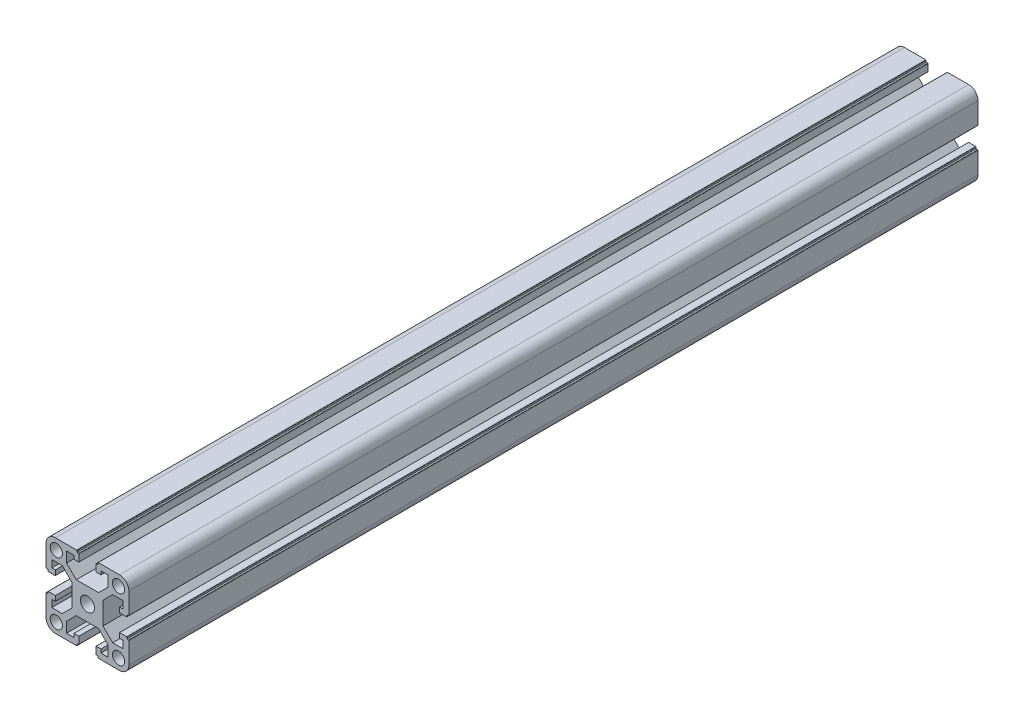
from build123d import *

# Parameters (mm, degrees)
SKETCH_1_R          = 2.95
SKETCH_1_R_2        = 3.4
EXTRUDE_1_DEPTH     = 205
SKETCH_2_R          = 4
CUT_EXTRUDE_1_DEPTH = 102


with BuildPart() as part:
    # 草图1 → 凸台-拉伸1 (new body, symmetric)
    with BuildSketch(Plane.XY.offset(50)):
        with BuildLine():
            Line((-1518.245004392, 3588.004280474), (-1518.245004392, 3582.975600817))
            Line((-1518.245004392, 3582.975600817), (-1522.916324736, 3578.304280474))
            Line((-1522.916324736, 3578.304280474), (-1533.673684048, 3578.304280474))
            Line((-1533.673684048, 3578.304280474), (-1538.345004392, 3582.975600817))
            Line((-1538.345004392, 3582.975600817), (-1538.345004392, 3588.004280474))
            Line((-1538.345004392, 3588.004280474), (-1534.845004392, 3588.004280474))
            Line((-1534.845004392, 3588.004280474), (-1534.845004392, 3586.304280474))
            Line((-1534.845004392, 3586.304280474), (-1532.445004392, 3586.304280474))
            Line((-1532.445004392, 3586.304280474), (-1532.445004392, 3589.704280474))
            ThreePointArc((-1532.445004392, 3589.704280474), (-1532.503583036, 3589.84570183), (-1532.645004392, 3589.904280474))
            Line((-1532.645004392, 3589.904280474), (-1533.345004392, 3589.904280474))
            Line((-1533.345004392, 3589.904280474), (-1533.345004392, 3590.604280474))
            ThreePointArc((-1533.345004392, 3590.604280474), (-1533.403583036, 3590.74570183), (-1533.545004392, 3590.804280474))
            Line((-1533.545004392, 3590.804280474), (-1543.795004392, 3590.804280474))
            ThreePointArc((-1543.795004392, 3590.804280474), (-1546.976984907, 3589.486260989), (-1548.295004392, 3586.304280474))
            Line((-1548.295004392, 3586.304280474), (-1548.295004392, 3576.054280474))
            ThreePointArc((-1548.295004392, 3576.054280474), (-1548.236425748, 3575.912859117), (-1548.095004392, 3575.854280474))
            Line((-1548.095004392, 3575.854280474), (-1547.395004392, 3575.854280474))
            Line((-1547.395004392, 3575.854280474), (-1547.395004392, 3575.154280474))
            ThreePointArc((-1547.395004392, 3575.154280474), (-1547.336425748, 3575.012859117), (-1547.195004392, 3574.954280474))
            Line((-1547.195004392, 3574.954280474), (-1543.795004392, 3574.954280474))
            Line((-1543.795004392, 3574.954280474), (-1543.795004392, 3577.354280474))
            Line((-1543.795004392, 3577.354280474), (-1545.495004392, 3577.354280474))
            Line((-1545.495004392, 3577.354280474), (-1545.495004392, 3580.854280474))
            Line((-1545.495004392, 3580.854280474), (-1540.466324736, 3580.854280474))
            Line((-1540.466324736, 3580.854280474), (-1535.795004392, 3576.18296013))
            Line((-1535.795004392, 3576.18296013), (-1535.795004392, 3565.425600817))
            Line((-1535.795004392, 3565.425600817), (-1540.466324736, 3560.754280474))
            Line((-1540.466324736, 3560.754280474), (-1545.495004392, 3560.754280474))
            Line((-1545.495004392, 3560.754280474), (-1545.495004392, 3564.254280474))
            Line((-1545.495004392, 3564.254280474), (-1543.795004392, 3564.254280474))
            Line((-1543.795004392, 3564.254280474), (-1543.795004392, 3566.654280474))
            Line((-1543.795004392, 3566.654280474), (-1547.195004392, 3566.654280474))
            ThreePointArc((-1547.195004392, 3566.654280474), (-1547.336425748, 3566.59570183), (-1547.395004392, 3566.454280474))
            Line((-1547.395004392, 3566.454280474), (-1547.395004392, 3565.754280474))
            Line((-1547.395004392, 3565.754280474), (-1548.095004392, 3565.754280474))
            ThreePointArc((-1548.095004392, 3565.754280474), (-1548.236425748, 3565.69570183), (-1548.295004392, 3565.554280474))
            Line((-1548.295004392, 3565.554280474), (-1548.295004392, 3555.304280474))
            ThreePointArc((-1548.295004392, 3555.304280474), (-1546.976984907, 3552.122299958), (-1543.795004392, 3550.804280474))
            Line((-1543.795004392, 3550.804280474), (-1533.545004392, 3550.804280474))
            ThreePointArc((-1533.545004392, 3550.804280474), (-1533.403583036, 3550.862859117), (-1533.345004392, 3551.004280474))
            Line((-1533.345004392, 3551.004280474), (-1533.345004392, 3551.704280474))
            Line((-1533.345004392, 3551.704280474), (-1532.645004392, 3551.704280474))
            ThreePointArc((-1532.645004392, 3551.704280474), (-1532.503583036, 3551.762859117), (-1532.445004392, 3551.904280474))
            Line((-1532.445004392, 3551.904280474), (-1532.445004392, 3555.304280474))
            Line((-1532.445004392, 3555.304280474), (-1534.845004392, 3555.304280474))
            Line((-1534.845004392, 3555.304280474), (-1534.845004392, 3553.604280474))
            Line((-1534.845004392, 3553.604280474), (-1538.345004392, 3553.604280474))
            Line((-1538.345004392, 3553.604280474), (-1538.345004392, 3558.63296013))
            Line((-1538.345004392, 3558.63296013), (-1533.673684048, 3563.304280474))
            Line((-1533.673684048, 3563.304280474), (-1522.916324736, 3563.304280474))
            Line((-1522.916324736, 3563.304280474), (-1518.245004392, 3558.63296013))
            Line((-1518.245004392, 3558.63296013), (-1518.245004392, 3553.604280474))
            Line((-1518.245004392, 3553.604280474), (-1521.745004392, 3553.604280474))
            Line((-1521.745004392, 3553.604280474), (-1521.745004392, 3555.304280474))
            Line((-1521.745004392, 3555.304280474), (-1524.145004392, 3555.304280474))
            Line((-1524.145004392, 3555.304280474), (-1524.145004392, 3551.904280474))
            ThreePointArc((-1524.145004392, 3551.904280474), (-1524.086425748, 3551.762859117), (-1523.945004392, 3551.704280474))
            Line((-1523.945004392, 3551.704280474), (-1523.245004392, 3551.704280474))
            Line((-1523.245004392, 3551.704280474), (-1523.245004392, 3551.004280474))
            ThreePointArc((-1523.245004392, 3551.004280474), (-1523.186425748, 3550.862859117), (-1523.045004392, 3550.804280474))
            Line((-1523.045004392, 3550.804280474), (-1512.795004392, 3550.804280474))
            ThreePointArc((-1512.795004392, 3550.804280474), (-1509.613023877, 3552.122299958), (-1508.295004392, 3555.304280474))
            Line((-1508.295004392, 3555.304280474), (-1508.295004392, 3565.554280474))
            ThreePointArc((-1508.295004392, 3565.554280474), (-1508.353583036, 3565.69570183), (-1508.495004392, 3565.754280474))
            Line((-1508.495004392, 3565.754280474), (-1509.195004392, 3565.754280474))
            Line((-1509.195004392, 3565.754280474), (-1509.195004392, 3566.454280474))
            ThreePointArc((-1509.195004392, 3566.454280474), (-1509.253583036, 3566.59570183), (-1509.395004392, 3566.654280474))
            Line((-1509.395004392, 3566.654280474), (-1512.795004392, 3566.654280474))
            Line((-1512.795004392, 3566.654280474), (-1512.795004392, 3564.254280474))
            Line((-1512.795004392, 3564.254280474), (-1511.095004392, 3564.254280474))
            Line((-1511.095004392, 3564.254280474), (-1511.095004392, 3560.754280474))
            Line((-1511.095004392, 3560.754280474), (-1516.123684048, 3560.754280474))
            Line((-1516.123684048, 3560.754280474), (-1520.795004392, 3565.425600817))
            Line((-1520.795004392, 3565.425600817), (-1520.795004392, 3576.18296013))
            Line((-1520.795004392, 3576.18296013), (-1516.123684048, 3580.854280474))
            Line((-1516.123684048, 3580.854280474), (-1511.095004392, 3580.854280474))
            Line((-1511.095004392, 3580.854280474), (-1511.095004392, 3577.354280474))
            Line((-1511.095004392, 3577.354280474), (-1512.795004392, 3577.354280474))
            Line((-1512.795004392, 3577.354280474), (-1512.795004392, 3574.954280474))
            Line((-1512.795004392, 3574.954280474), (-1509.395004392, 3574.954280474))
            ThreePointArc((-1509.395004392, 3574.954280474), (-1509.253583036, 3575.012859117), (-1509.195004392, 3575.154280474))
            Line((-1509.195004392, 3575.154280474), (-1509.195004392, 3575.854280474))
            Line((-1509.195004392, 3575.854280474), (-1508.495004392, 3575.854280474))
            ThreePointArc((-1508.495004392, 3575.854280474), (-1508.353583036, 3575.912859117), (-1508.295004392, 3576.054280474))
            Line((-1508.295004392, 3576.054280474), (-1508.295004392, 3586.304280474))
            ThreePointArc((-1508.295004392, 3586.304280474), (-1509.613023877, 3589.486260989), (-1512.795004392, 3590.804280474))
            Line((-1512.795004392, 3590.804280474), (-1523.045004392, 3590.804280474))
            ThreePointArc((-1523.045004392, 3590.804280474), (-1523.186425748, 3590.74570183), (-1523.245004392, 3590.604280474))
            Line((-1523.245004392, 3590.604280474), (-1523.245004392, 3589.904280474))
            Line((-1523.245004392, 3589.904280474), (-1523.945004392, 3589.904280474))
            ThreePointArc((-1523.945004392, 3589.904280474), (-1524.086425748, 3589.84570183), (-1524.145004392, 3589.704280474))
            Line((-1524.145004392, 3589.704280474), (-1524.145004392, 3586.304280474))
            Line((-1524.145004392, 3586.304280474), (-1521.745004392, 3586.304280474))
            Line((-1521.745004392, 3586.304280474), (-1521.745004392, 3588.004280474))
            Line((-1521.745004392, 3588.004280474), (-1518.245004392, 3588.004280474))
        make_face()
        with Locations((-1513.270004392, 3555.779280474)):
            Circle(SKETCH_1_R, mode=Mode.SUBTRACT)
        with Locations((-1528.295004392, 3570.804280474)):
            Circle(SKETCH_1_R_2, mode=Mode.SUBTRACT)
        with Locations((-1513.270004392, 3585.829280474)):
            Circle(SKETCH_1_R, mode=Mode.SUBTRACT)
        with Locations((-1543.320004392, 3585.829280474)):
            Circle(SKETCH_1_R, mode=Mode.SUBTRACT)
        with Locations((-1543.320004392, 3555.779280474)):
            Circle(SKETCH_1_R, mode=Mode.SUBTRACT)
    extrude(amount=EXTRUDE_1_DEPTH, both=True)

    # 草图2 → 切除-拉伸1 (cut)
    with BuildSketch(Plane(origin=(0, 3590.804280474, 0), x_dir=(1, 0, 0), z_dir=(0, 1, 0))):
        with Locations((-1528.295004392, 65)):
            Circle(SKETCH_2_R)
        with Locations((-1528.295004392, -165)):
            Circle(SKETCH_2_R)
    extrude(amount=-CUT_EXTRUDE_1_DEPTH, mode=Mode.SUBTRACT)


solid = part.part
